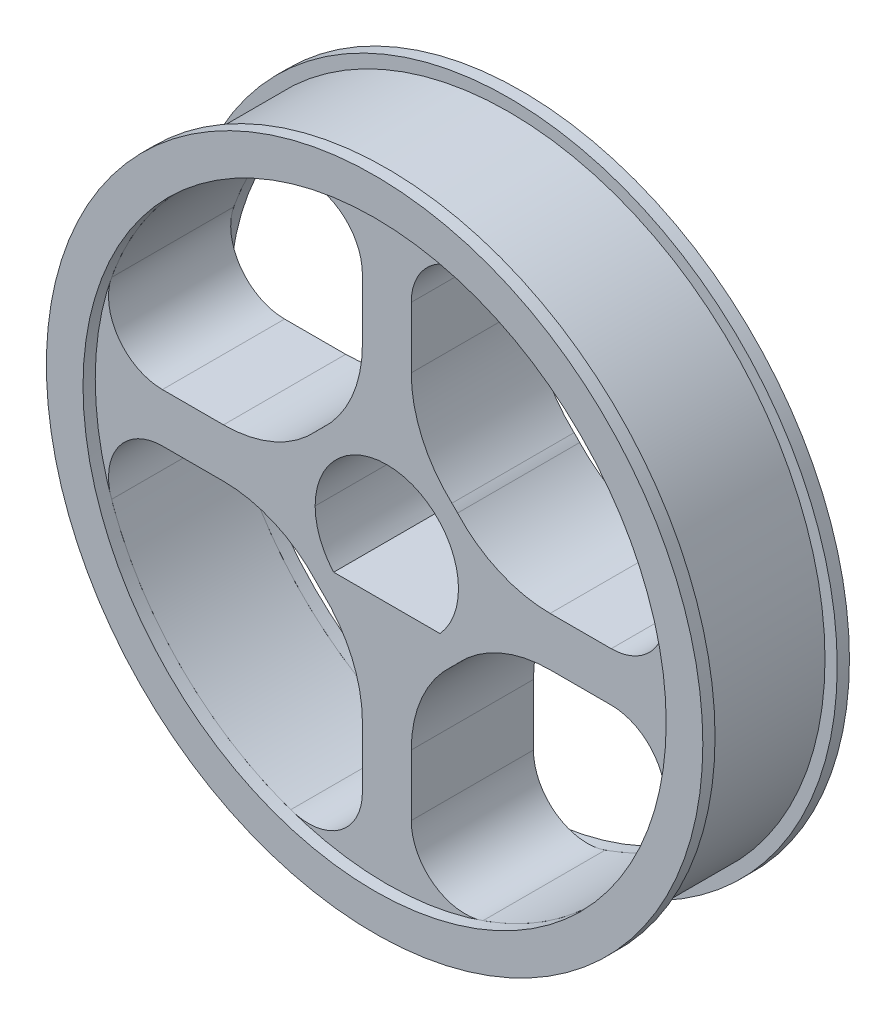
from build123d import *

# Parameters (mm, degrees)
SKETCH1_R           = 6.569999999
SKETCH1_R_2         = 6.061999999
SKETCH1_R_3         = 1.997999999
BOSS_EXTRUDE1_DEPTH = 1.27
BOSS_EXTRUDE2_START = 1.27
SKETCH1_5_R         = 6.823999999
SKETCH1_5_R_2       = 6.061999999
BOSS_EXTRUDE2_DEPTH = 0.254


with BuildPart() as part:
    # Sketch1 → Boss-Extrude1 (new, symmetric)
    with BuildSketch(Plane.XY):
        with Locations((-14.585173992, 6.361392546)):
            Circle(SKETCH1_R)
        with Locations((-14.585173992, 6.361392546)):
            Circle(SKETCH1_R_2, mode=Mode.SUBTRACT)
        with BuildLine():
            Line((-14.077173992, 9.756392545), (-14.077173992, 11.026392545))
            ThreePointArc((-14.077173992, 11.026392545), (-13.605249635, 11.940269174), (-12.586887207, 12.084564212))
            ThreePointArc((-12.586887207, 12.084564212), (-14.585173992, 12.423392545), (-16.583460777, 12.084564212))
            ThreePointArc((-16.583460777, 12.084564212), (-15.565098349, 11.940269174), (-15.093173992, 11.026392545))
            Line((-15.093173992, 11.026392545), (-15.093173992, 9.756392545))
            ThreePointArc((-15.093173992, 9.756392545), (-15.313620832, 8.705559935), (-15.937790686, 7.831913568))
            ThreePointArc((-15.937790686, 7.831913568), (-14.585173992, 8.359392545), (-13.232557298, 7.831913568))
            ThreePointArc((-13.232557298, 7.831913568), (-13.856727152, 8.705559935), (-14.077173992, 9.756392545))
        make_face()
        with BuildLine():
            ThreePointArc((-8.523173993, 6.361392546), (-8.608481319, 7.374797044), (-8.862002326, 8.35967933))
            ThreePointArc((-8.862002326, 8.35967933), (-9.006297363, 7.341316902), (-9.920173993, 6.869392546))
            Line((-9.920173993, 6.869392546), (-11.190173993, 6.869392546))
            ThreePointArc((-11.190173993, 6.869392546), (-12.241006602, 7.089839385), (-13.11465297, 7.714009239))
            ThreePointArc((-13.11465297, 7.714009239), (-12.723708843, 7.087306795), (-12.587173993, 6.361392546))
            ThreePointArc((-12.587173993, 6.361392546), (-12.723708843, 5.635478296), (-13.11465297, 5.008775852))
            ThreePointArc((-13.11465297, 5.008775852), (-12.241006602, 5.632945706), (-11.190173993, 5.853392546))
            Line((-11.190173993, 5.853392546), (-9.920173993, 5.853392546))
            ThreePointArc((-9.920173993, 5.853392546), (-9.006297363, 5.381468189), (-8.862002326, 4.363105761))
            ThreePointArc((-8.862002326, 4.363105761), (-8.608481319, 5.347988047), (-8.523173993, 6.361392546))
        make_face()
        with BuildLine():
            ThreePointArc((-19.250173991, 6.869392546), (-20.164050621, 7.341316902), (-20.308345658, 8.35967933))
            ThreePointArc((-20.308345658, 8.35967933), (-20.647173991, 6.361392546), (-20.308345658, 4.363105761))
            ThreePointArc((-20.308345658, 4.363105761), (-20.164050621, 5.381468189), (-19.250173991, 5.853392546))
            Line((-19.250173991, 5.853392546), (-17.980173991, 5.853392546))
            ThreePointArc((-17.980173991, 5.853392546), (-16.929341382, 5.632945706), (-16.055695014, 5.008775852))
            ThreePointArc((-16.055695014, 5.008775852), (-16.583173991, 6.361392546), (-16.055695014, 7.714009239))
            ThreePointArc((-16.055695014, 7.714009239), (-16.929341382, 7.089839385), (-17.980173991, 6.869392546))
            Line((-17.980173991, 6.869392546), (-19.250173991, 6.869392546))
        make_face()
        with BuildLine():
            ThreePointArc((-16.583460777, 0.63822088), (-14.585173992, 0.299392546), (-12.586887207, 0.63822088))
            ThreePointArc((-12.586887207, 0.63822088), (-13.605249635, 0.782515917), (-14.077173992, 1.696392546))
            Line((-14.077173992, 1.696392546), (-14.077173992, 2.966392546))
            ThreePointArc((-14.077173992, 2.966392546), (-13.856727152, 4.017225156), (-13.232557298, 4.890871523))
            ThreePointArc((-13.232557298, 4.890871523), (-14.585173992, 4.363392546), (-15.937790686, 4.890871523))
            ThreePointArc((-15.937790686, 4.890871523), (-15.313620832, 4.017225156), (-15.093173992, 2.966392546))
            Line((-15.093173992, 2.966392546), (-15.093173992, 1.696392546))
            ThreePointArc((-15.093173992, 1.696392546), (-15.565098349, 0.782515917), (-16.583460777, 0.63822088))
        make_face()
        with Locations((-14.585173992, 6.361392546)):
            Circle(SKETCH1_R_3)
        with BuildLine():
            add(Edge.make_bspline(
                [(-13.480592623, 5.361392545), (-13.460539436, 5.384341171), (-13.420470859, 5.430195167), (-13.365842841, 5.503511201), (-13.307154336, 5.59247995), (-13.248045319, 5.69918428), (-13.192924177, 5.824787769), (-13.14943929, 5.954910636), (-13.118404819, 6.088487495), (-13.098791679, 6.224357356), (-13.096379888, 6.315714149), (-13.095173993, 6.361392546)],
                knots=[0, 0, 0, 0, 0.083397986, 0.166638776, 0.250036761, 0.375030634, 0.500024507, 0.62501838, 0.750012254, 0.875006127, 1, 1, 1, 1], degree=3))
            ThreePointArc((-13.095173993, 6.361392546), (-14.585173992, 7.851392545), (-16.075173991, 6.361392546))
            add(Edge.make_bspline(
                [(-16.075173991, 6.361392546), (-16.074638254, 6.330921531), (-16.073567789, 6.270036937), (-16.064859774, 6.179022479), (-16.04865674, 6.073679037), (-16.020862372, 5.954905457), (-15.977427672, 5.824797796), (-15.922333529, 5.699149352), (-15.85569141, 5.579296345), (-15.779043389, 5.46540879), (-15.719518037, 5.396064627), (-15.689755361, 5.361392545)],
                knots=[0, 0, 0, 0, 0.083397986, 0.166638774, 0.25003676, 0.375030634, 0.500024507, 0.62501838, 0.750012253, 0.875006126, 1, 1, 1, 1], degree=3))
            Line((-15.689755361, 5.361392545), (-13.480592623, 5.361392545))
        make_face(mode=Mode.SUBTRACT)
    extrude(amount=BOSS_EXTRUDE1_DEPTH, both=True)


with BuildPart() as body_2:
    # Sketch1_5 → Boss-Extrude2 (new body)
    with BuildSketch(Plane.XY.offset(BOSS_EXTRUDE2_START)):
        with Locations((-14.585173992, 6.361392546)):
            Circle(SKETCH1_5_R)
        with Locations((-14.585173992, 6.361392546)):
            Circle(SKETCH1_5_R_2, mode=Mode.SUBTRACT)
    extrude(amount=BOSS_EXTRUDE2_DEPTH)


with BuildPart() as body_3:
    # Mirror2: mirrored copy
    add(body_2.part.mirror(Plane.XY))


solid = Compound([part.part, body_2.part, body_3.part])
